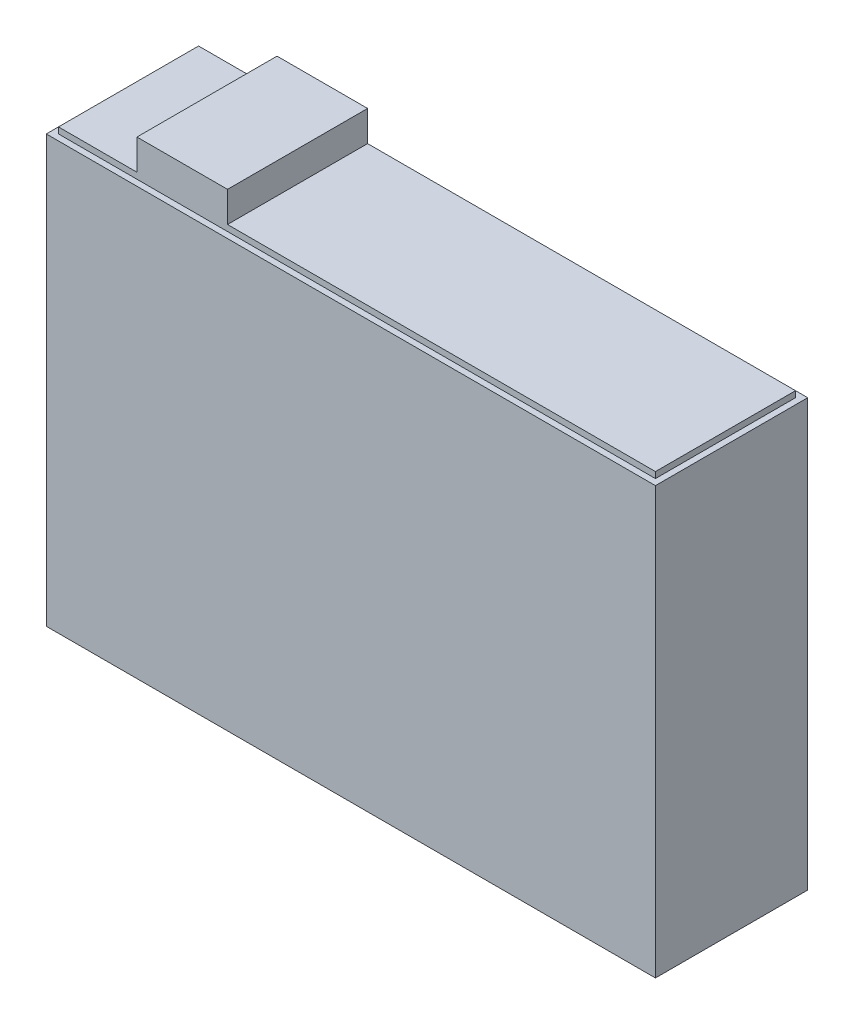
from build123d import *

# Parameters (mm, degrees)
SKETCH1_W           = 10
SKETCH1_H           = 2.5
BOSS_EXTRUDE1_DEPTH = 7
SKETCH2_W           = 9.8
SKETCH2_H           = 2.3
BOSS_EXTRUDE2_DEPTH = 0.1
SKETCH3_W           = 1.487009638
SKETCH3_H           = 2.3
BOSS_EXTRUDE3_DEPTH = 0.5


with BuildPart() as part:
    # Sketch1 → Boss-Extrude1 (new body)
    with BuildSketch(Plane(origin=(0, 0, 0), x_dir=(1, 0, 0), z_dir=(0, 1, 0))):
        Rectangle(SKETCH1_W, SKETCH1_H)
    extrude(amount=BOSS_EXTRUDE1_DEPTH)

    # Sketch2 → Boss-Extrude2 (add)
    with BuildSketch(Plane(origin=(0, 7, 0), x_dir=(1, 0, 0), z_dir=(0, 1, 0))):
        Rectangle(SKETCH2_W, SKETCH2_H)
    extrude(amount=BOSS_EXTRUDE2_DEPTH)

    # Sketch3 → Boss-Extrude3 (add)
    with BuildSketch(Plane(origin=(0, 7.1, 0), x_dir=(1, 0, 0), z_dir=(0, 1, 0))):
        with Locations((-2.868353266, 0)):
            Rectangle(SKETCH3_W, SKETCH3_H)
    extrude(amount=BOSS_EXTRUDE3_DEPTH)


solid = part.part
